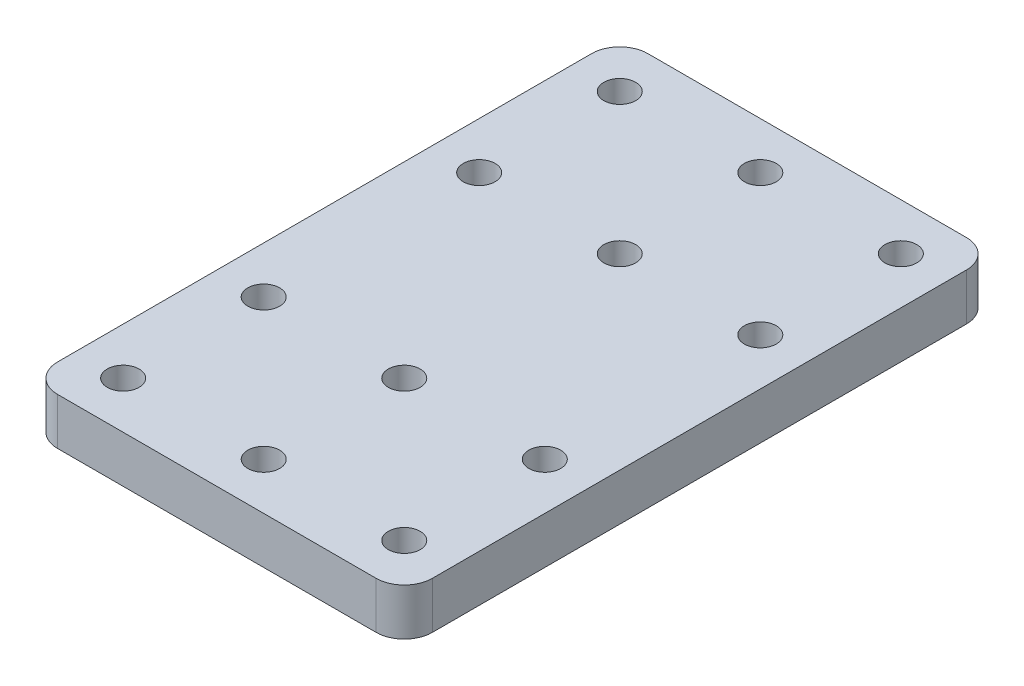
from build123d import *

# Parameters (mm, degrees)
SKETCH_1_W      = 40
SKETCH_1_H      = 63
SKETCH_1_R      = 1.7
EXTRUDE_1_DEPTH = 5
FILLET_1_R      = 3


with BuildPart() as part:
    # ｽｹｯﾁ1 → ﾎﾞｽ - 押し出し1 (new body)
    with BuildSketch(Plane(origin=(0, 0, 0), x_dir=(1, 0, 0), z_dir=(0, 1, 0))):
        Rectangle(SKETCH_1_W, SKETCH_1_H)
        with Locations((-15, 26.5)):
            Circle(SKETCH_1_R, mode=Mode.SUBTRACT)
        with Locations((0, 26.5)):
            Circle(SKETCH_1_R, mode=Mode.SUBTRACT)
        with Locations((15, 26.5)):
            Circle(SKETCH_1_R, mode=Mode.SUBTRACT)
        with Locations((0, 11.5)):
            Circle(SKETCH_1_R, mode=Mode.SUBTRACT)
        with Locations((-15, 11.5)):
            Circle(SKETCH_1_R, mode=Mode.SUBTRACT)
        with Locations((15, 11.5)):
            Circle(SKETCH_1_R, mode=Mode.SUBTRACT)
        with Locations((-15, -11.5)):
            Circle(SKETCH_1_R, mode=Mode.SUBTRACT)
        with Locations((0, -11.5)):
            Circle(SKETCH_1_R, mode=Mode.SUBTRACT)
        with Locations((15, -11.5)):
            Circle(SKETCH_1_R, mode=Mode.SUBTRACT)
        with Locations((-15, -26.5)):
            Circle(SKETCH_1_R, mode=Mode.SUBTRACT)
        with Locations((0, -26.5)):
            Circle(SKETCH_1_R, mode=Mode.SUBTRACT)
        with Locations((15, -26.5)):
            Circle(SKETCH_1_R, mode=Mode.SUBTRACT)
    extrude(amount=EXTRUDE_1_DEPTH)

    # ﾌｨﾚｯﾄ1
    fillet_1_edges = [part.edges().sort_by_distance(p)[0] for p in [
        (20, 2.5, 31.5),
        (-20, 2.5, 31.5),
        (-20, 2.5, -31.5),
        (20, 2.5, -31.5),
    ]]
    fillet(fillet_1_edges, radius=FILLET_1_R)


solid = part.part
